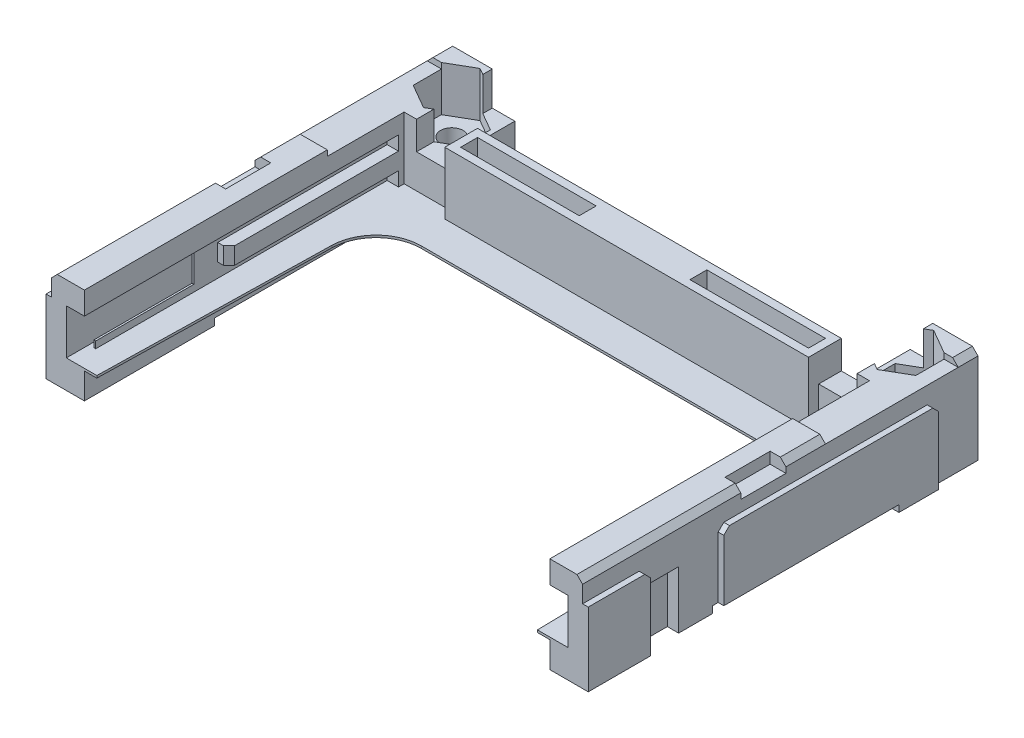
from build123d import *

# Parameters (mm, degrees)
EXTRUIR1_DEPTH         = 9.9
CROQUIS2_R             = 1
CORTAR_EXTRUIR1_DEPTH  = 15.9
CORTAR_EXTRUIR2_DEPTH  = 4
CROQUIS4_W             = 35
CROQUIS4_H             = 2.727458855
CORTAR_EXTRUIR3_DEPTH  = 24
CROQUIS5_W             = 35
CROQUIS5_H             = 3.2
CORTAR_EXTRUIR4_DEPTH  = 8.5
CROQUIS6_W             = 39
CROQUIS6_H             = 14.452712812
CORTAR_EXTRUIR5_DEPTH  = 3
EXTRUIR2_DEPTH         = 0.2
CROQUIS8_W             = 49.57319474
CROQUIS8_H             = 11.75
CORTAR_EXTRUIR6_DEPTH  = 0.5
CROQUIS9_W             = 2.460261438
CROQUIS9_H             = 4
CORTAR_EXTRUIR7_DEPTH  = 1
CHAFL_N1_SIZE          = 0.5
CHAFL_N2_SIZE          = 0.5
CROQUIS10_W            = 32.2
CROQUIS10_H            = 2.9
EXTRUIR3_DEPTH         = 5.5
CROQUIS11_W            = 10.5
CROQUIS11_H            = 1.5
CORTAR_EXTRUIR8_DEPTH  = 2.5
CROQUIS12_W            = 16
CROQUIS12_H            = 2
CORTAR_EXTRUIR9_DEPTH  = 57.5
CROQUIS13_W            = 35
CROQUIS13_H            = 3.2
CORTAR_EXTRUIR10_DEPTH = 0.7
CROQUIS15_W            = 5.5
CROQUIS15_H            = 7.9
EXTRUIR4_DEPTH         = 0.5
CHAFL_N3_SIZE          = 0.5
CROQUIS16_W            = 3
CROQUIS16_H            = 6.5
CORTAR_EXTRUIR11_DEPTH = 1
CHAFL_N4_SIZE          = 0.5
CORTAR_EXTRUIR12_DEPTH = 1
CHAFL_N5_SIZE          = 0.5
CHAFL_N6_SIZE          = 0.5
CROQUIS18_W            = 0.4398817
CROQUIS18_H            = 4
CORTAR_EXTRUIR13_DEPTH = 22
CROQUIS19_W            = 10.696044144
CROQUIS19_H            = 2.8
CORTAR_EXTRUIR14_DEPTH = 0.2
CROQUIS20_W            = 2
CROQUIS20_H            = 4
CORTAR_EXTRUIR15_DEPTH = 0.2
CROQUIS21_W            = 42.865199157
CROQUIS21_H            = 3.067417921
CORTAR_EXTRUIR16_DEPTH = 58


with BuildPart() as part:
    # Croquis1 → Extruir1 (new body)
    with BuildSketch(Plane(origin=(0, 0, 0), x_dir=(1, 0, 0), z_dir=(0, 1, 0))):
        Polygon((23.5, 0), (-23.5, 0), (-23.5, -35), (-20.6, -35), (-20.6, -6.7), (20.6, -6.7), (20.6, -35), (23.5, -35), align=None)
    extrude(amount=EXTRUIR1_DEPTH)

    # Croquis2 → Cortar-Extruir1 (cut)
    with BuildSketch(Plane(origin=(0, 9.9, 0), x_dir=(-1, 0, 0), z_dir=(0, 1, 0))):
        with Locations((-20.08, 3)):
            Circle(CROQUIS2_R)
        with Locations((20.08, 3)):
            Circle(CROQUIS2_R)
    extrude(amount=-CORTAR_EXTRUIR1_DEPTH, mode=Mode.SUBTRACT)

    # Croquis3 → Cortar-Extruir2 (cut)
    with BuildSketch(Plane(origin=(0, 9.9, 0), x_dir=(-1, 0, 0), z_dir=(0, 1, 0))):
        Polygon((-20.08, 5.5), (-22.245063509, 4.25), (-22.245063509, 1.75), (-20.08, 0.5), (-17.914936491, 1.75), (-17.914936491, 4.25), align=None)
        Polygon((20.08, 5.5), (17.914936491, 4.25), (17.914936491, 1.75), (20.08, 0.5), (22.245063509, 1.75), (22.245063509, 4.25), align=None)
    extrude(amount=-CORTAR_EXTRUIR2_DEPTH, mode=Mode.SUBTRACT)

    # Croquis4 → Cortar-Extruir3 (cut)
    with BuildSketch(Plane(origin=(0, 9.9, 0), x_dir=(-1, 0, 0), z_dir=(0, 1, 0))):
        with Locations((0, 0.136270572)):
            Rectangle(CROQUIS4_W, CROQUIS4_H)
    extrude(amount=-CORTAR_EXTRUIR3_DEPTH, mode=Mode.SUBTRACT)

    # Croquis5 → Cortar-Extruir4 (cut)
    with BuildSketch(Plane(origin=(0, 9.9, 0), x_dir=(-1, 0, 0), z_dir=(0, 1, 0))):
        with Locations((0, 3.1)):
            Rectangle(CROQUIS5_W, CROQUIS5_H)
    extrude(amount=-CORTAR_EXTRUIR4_DEPTH, mode=Mode.SUBTRACT)

    # Croquis6 → Cortar-Extruir5 (cut)
    with BuildSketch(Plane(origin=(0, 9.9, 0), x_dir=(-1, 0, 0), z_dir=(0, 1, 0))):
        with Locations((0, 5.388219545)):
            Rectangle(CROQUIS6_W, CROQUIS6_H)
    extrude(amount=-CORTAR_EXTRUIR5_DEPTH, mode=Mode.SUBTRACT)

    # Croquis7 → Extruir2 (add)
    with BuildSketch(Plane(origin=(0, 3.9, 0), x_dir=(-1, 0, 0), z_dir=(0, 1, 0))):
        with BuildLine():
            Line((-20.6, 35), (-19.5, 35))
            Line((-19.5, 35), (-19.080611376, 14.617712891))
            ThreePointArc((-19.080611376, 14.617712891), (-17.880640918, 11.842628092), (-15.081457862, 10.7))
            Line((-15.081457862, 10.7), (15.081457862, 10.7))
            ThreePointArc((15.081457862, 10.7), (17.880640918, 11.842628092), (19.080611376, 14.617712891))
            Line((19.080611376, 14.617712891), (19.5, 35))
            Line((19.5, 35), (20.6, 35))
            Line((20.6, 35), (20.6, 6.7))
            Line((20.6, 6.7), (-20.6, 6.7))
            Line((-20.6, 6.7), (-20.6, 35))
        make_face()
    extrude(amount=-EXTRUIR2_DEPTH)

    # Croquis8 → Cortar-Extruir6 (cut)
    with BuildSketch(Plane(origin=(0, 9.9, 0), x_dir=(-1, 0, 0), z_dir=(0, 1, 0))):
        with Locations((0.155531932, 7.625)):
            Rectangle(CROQUIS8_W, CROQUIS8_H)
    extrude(amount=-CORTAR_EXTRUIR6_DEPTH, mode=Mode.SUBTRACT)

    # Croquis9 → Cortar-Extruir7 (cut)
    with BuildSketch(Plane(origin=(0, 9.9, 0), x_dir=(-1, 0, 0), z_dir=(0, 1, 0))):
        with Locations((23.330130719, 19)):
            Rectangle(CROQUIS9_W, CROQUIS9_H)
        with Locations((-23.330130719, 19)):
            Rectangle(CROQUIS9_W, CROQUIS9_H)
    extrude(amount=-CORTAR_EXTRUIR7_DEPTH, mode=Mode.SUBTRACT)

    # Chaflán1
    chafl_n1_edges = [part.edges().sort_by_distance(p)[0] for p in [
        (23.5, 9.9, 15.25),
        (23.5, 9.9, 28),
        (-23.5, 9.9, 28),
        (-23.5, 9.9, 15.25),
    ]]
    chamfer(chafl_n1_edges, length=CHAFL_N1_SIZE)

    # Chaflán2
    chafl_n2_edges = [part.edges().sort_by_distance(p)[0] for p in [
        (23.5, 9.9, 0.875),
        (-23.5, 9.9, 0.875),
    ]]
    chamfer(chafl_n2_edges, length=CHAFL_N2_SIZE)

    # Croquis10 → Extruir3 (add)
    with BuildSketch(Plane(origin=(0, 9.4, 0), x_dir=(-1, 0, 0), z_dir=(0, 1, 0))):
        with Locations((0, 6.15)):
            Rectangle(CROQUIS10_W, CROQUIS10_H)
    extrude(amount=-EXTRUIR3_DEPTH)

    # Croquis11 → Cortar-Extruir8 (cut)
    with BuildSketch(Plane(origin=(0, 9.4, 0), x_dir=(-1, 0, 0), z_dir=(0, 1, 0))):
        with Locations((-10.15, 6.15)):
            Rectangle(CROQUIS11_W, CROQUIS11_H)
        with Locations((10.15, 6.15)):
            Rectangle(CROQUIS11_W, CROQUIS11_H)
    extrude(amount=-CORTAR_EXTRUIR8_DEPTH, mode=Mode.SUBTRACT)

    # Croquis12 → Cortar-Extruir9 (cut)
    with BuildSketch(Plane.ZY.offset(23.5)):
        with Locations((15.5, 1)):
            Rectangle(CROQUIS12_W, CROQUIS12_H)
    extrude(amount=-CORTAR_EXTRUIR9_DEPTH, mode=Mode.SUBTRACT)

    # Croquis13 → Cortar-Extruir10 (cut)
    with BuildSketch(Plane.XZ):
        with Locations((0, 3.1)):
            Rectangle(CROQUIS13_W, CROQUIS13_H)
    extrude(amount=-CORTAR_EXTRUIR10_DEPTH, mode=Mode.SUBTRACT)

    # Croquis15 → Extruir4 (add)
    with BuildSketch(Plane.ZY.offset(23.5)):
        Polygon((4, 0), (4, 7.9), (23, 7.9), (23, 2), (7.5, 2), (7.5, 0), align=None)
        with Locations((32.25, 3.95)):
            Rectangle(CROQUIS15_W, CROQUIS15_H)
    extruir4 = extrude(amount=EXTRUIR4_DEPTH)

    # Chaflán3
    chafl_n3_edges = [part.edges().sort_by_distance(p)[0] for p in [
        (-23.75, 7.9, 29.5),
        (-23.75, 7.9, 23),
        (-23.75, 7.9, 4),
    ]]
    chamfer(chafl_n3_edges, length=CHAFL_N3_SIZE)

    # Croquis16 → Cortar-Extruir11 (cut)
    with BuildSketch(Plane.ZY.offset(23.5)):
        with Locations((28, 3.25)):
            Rectangle(CROQUIS16_W, CROQUIS16_H)
    cortar_extruir11 = extrude(amount=-CORTAR_EXTRUIR11_DEPTH, mode=Mode.SUBTRACT)

    # Simetría1: Extruir4, Cortar-Extruir11 across plane
    add(extruir4.mirror(Plane(origin=(0, 0, 0), x_dir=(0, 0, 1), z_dir=(1, 0, 0))))
    add(cortar_extruir11.mirror(Plane(origin=(0, 0, 0), x_dir=(0, 0, 1), z_dir=(1, 0, 0))), mode=Mode.SUBTRACT)

    # Chaflán4
    chafl_n4_edges = [part.edges().sort_by_distance(p)[0] for p in [
        (23.75, 7.9, 4),
        (23.75, 7.9, 23),
        (23.75, 7.9, 29.5),
    ]]
    chamfer(chafl_n4_edges, length=CHAFL_N4_SIZE)

    # Croquis17 → Cortar-Extruir12 (cut)
    with BuildSketch(Plane(origin=(-20.6, 0, 0), x_dir=(0, 0, -1), z_dir=(1, 0, 0))):
        Polygon((-35, 7.9), (-7.2, 7.9), (-7.2, 6.65), (-22.2, 6.65), (-22.2, 5.15), (-7.2, 5.15), (-7.2, 3.9), (-35, 3.9), align=None)
    cortar_extruir12 = extrude(amount=-CORTAR_EXTRUIR12_DEPTH, mode=Mode.SUBTRACT)

    # Chaflán5
    chafl_n5_edges = [part.edges().sort_by_distance(p)[0] for p in [
        (-20.6, 5.9, 22.2),
    ]]
    chamfer(chafl_n5_edges, length=CHAFL_N5_SIZE)

    # Simetría2: Cortar-Extruir12 across plane
    add(cortar_extruir12.mirror(Plane(origin=(0, 0, 0), x_dir=(0, 0, 1), z_dir=(1, 0, 0))), mode=Mode.SUBTRACT)

    # Chaflán6
    chafl_n6_edges = [part.edges().sort_by_distance(p)[0] for p in [
        (20.6, 5.9, 22.2),
    ]]
    chamfer(chafl_n6_edges, length=CHAFL_N6_SIZE)

    # Croquis18 → Cortar-Extruir13 (cut)
    with BuildSketch(Plane.XY.offset(35)):
        with Locations((-21.98005915, 5.9)):
            Rectangle(CROQUIS18_W, CROQUIS18_H)
        with Locations((21.98005915, 5.9)):
            Rectangle(CROQUIS18_W, CROQUIS18_H)
    extrude(amount=-CORTAR_EXTRUIR13_DEPTH, mode=Mode.SUBTRACT)

    # Croquis19 → Cortar-Extruir14 (cut)
    with BuildSketch(Plane(origin=(-21.6, 0, 0), x_dir=(0, 0, -1), z_dir=(1, 0, 0))):
        with Locations((-29.651977928, 5.9)):
            Rectangle(CROQUIS19_W, CROQUIS19_H)
    cortar_extruir14 = extrude(amount=-CORTAR_EXTRUIR14_DEPTH, mode=Mode.SUBTRACT)

    # Croquis20 → Cortar-Extruir15 (cut)
    with BuildSketch(Plane(origin=(-21.6, 0, 0), x_dir=(0, 0, -1), z_dir=(1, 0, 0))):
        with Locations((-34, 5.9)):
            Rectangle(CROQUIS20_W, CROQUIS20_H)
    cortar_extruir15 = extrude(amount=-CORTAR_EXTRUIR15_DEPTH, mode=Mode.SUBTRACT)

    # Simetría3: Cortar-Extruir14, Cortar-Extruir15 across plane
    add(cortar_extruir14.mirror(Plane(origin=(0, 0, 0), x_dir=(0, 0, 1), z_dir=(1, 0, 0))), mode=Mode.SUBTRACT)
    add(cortar_extruir15.mirror(Plane(origin=(0, 0, 0), x_dir=(0, 0, 1), z_dir=(1, 0, 0))), mode=Mode.SUBTRACT)

    # Croquis21 → Cortar-Extruir16 (cut)
    with BuildSketch(Plane(origin=(24, 0, 0), x_dir=(0, 0, -1), z_dir=(1, 0, 0))):
        with Locations((-17.067402922, -0.133708961)):
            Rectangle(CROQUIS21_W, CROQUIS21_H)
    extrude(amount=-CORTAR_EXTRUIR16_DEPTH, mode=Mode.SUBTRACT)


solid = part.part
